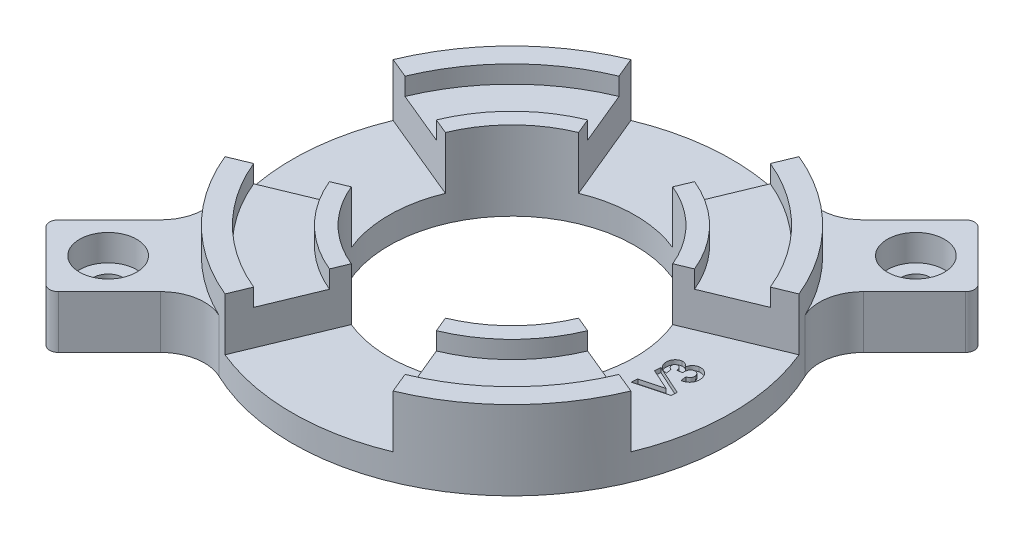
from build123d import *

# Parameters (mm, degrees)
SKETCH1_R                      = 25
SKETCH1_R_2                    = 14
BOSS_EXTRUDE1_DEPTH            = 7
SKETCH3_R                      = 25
SKETCH3_R_2                    = 22.5
BOSS_EXTRUDE2_DEPTH            = 2
SKETCH5_R                      = 15.9
SKETCH5_R_2                    = 14
BOSS_EXTRUDE3_DEPTH            = 2
CUT_EXTRUDE1_DEPTH             = 6
CIRPATTERN1_COUNT              = 4
BOSS_EXTRUDE4_DEPTH            = 6
CBORE_FOR_M3_SHCS1_D           = 3.4
CBORE_FOR_M3_SHCS1_CBORE_D     = 6.5
CBORE_FOR_M3_SHCS1_CBORE_DEPTH = 3
FILLET1_R                      = 5
FILLET1_OF_MIRROR1_R           = 5
FILLET2_R                      = 1
CUT_EXTRUDE2_DEPTH             = 0.5


with BuildPart() as part:
    # Sketch1 → Boss-Extrude1 (new body)
    with BuildSketch(Plane(origin=(0, 0, 0), x_dir=(1, 0, 0), z_dir=(0, 1, 0))):
        with Locations(Location((0, 0, 0), (0, 0, 270))):
            Circle(SKETCH1_R)
        with Locations(Location((0, 0, 0), (0, 0, 270))):
            Circle(SKETCH1_R_2, mode=Mode.SUBTRACT)
    extrude(amount=BOSS_EXTRUDE1_DEPTH)

    # Sketch3 → Boss-Extrude2 (add)
    with BuildSketch(Plane(origin=(0, 7, 0), x_dir=(1, 0, 0), z_dir=(0, 1, 0))):
        with Locations(Location((0, 0, 0), (0, 0, 270))):
            Circle(SKETCH3_R)
        with Locations(Location((0, 0, 0), (0, 0, 270))):
            Circle(SKETCH3_R_2, mode=Mode.SUBTRACT)
    extrude(amount=BOSS_EXTRUDE2_DEPTH)

    # Sketch5 → Boss-Extrude3 (add, through all)
    with BuildSketch(Plane(origin=(0, 7, 0), x_dir=(1, 0, 0), z_dir=(0, 1, 0))):
        with Locations(Location((0, 0, 0), (0, 0, 270))):
            Circle(SKETCH5_R)
        with Locations(Location((0, 0, 0), (0, 0, 270))):
            Circle(SKETCH5_R_2, mode=Mode.SUBTRACT)
    extrude(amount=BOSS_EXTRUDE3_DEPTH)

    # Sketch4 → Cut-Extrude1 (cut)
    with BuildSketch(Plane(origin=(0, 9, 0), x_dir=(1, 0, 0), z_dir=(0, 1, 0))):
        with BuildLine():
            Line((0, 0), (-9.567085809, 23.096988313))
            ThreePointArc((-9.567085809, 23.096988313), (0, 25), (9.567085809, 23.096988313))
            Line((9.567085809, 23.096988313), (0, 0))
        make_face()
    cut_extrude1 = extrude(amount=-CUT_EXTRUDE1_DEPTH, mode=Mode.SUBTRACT)

    # CirPattern1: Cut-Extrude1 ×4 about axis
    cirpattern1_axis = Axis((0, 9, 0), (0, -1, 0))
    for i in range(1, CIRPATTERN1_COUNT):
        add(cut_extrude1.rotate(cirpattern1_axis, i * 360 / CIRPATTERN1_COUNT), mode=Mode.SUBTRACT)

    # Sketch6 → Boss-Extrude4 (add)
    with BuildSketch(Plane.XZ):
        with BuildLine():
            Line((-30.0520382, 22.980970389), (-22.980970389, 30.0520382))
            Line((-22.980970389, 30.0520382), (-13.78497417, 20.856041982))
            ThreePointArc((-13.78497417, 20.856041982), (-17.67766953, 17.67766953), (-20.856041982, 13.78497417))
            Line((-20.856041982, 13.78497417), (-30.0520382, 22.980970389))
        make_face()
    boss_extrude4 = extrude(amount=-BOSS_EXTRUDE4_DEPTH)

    # CBORE for M3 SHCS1 (through all)
    with Locations(Plane(origin=(0, 6, 0), x_dir=(1, 0, 0), z_dir=(0, 1, 0))):
        with Locations((-22.980970389, -22.980970389)):
            cbore_for_m3_shcs1 = CounterBoreHole(CBORE_FOR_M3_SHCS1_D / 2, CBORE_FOR_M3_SHCS1_CBORE_D / 2, CBORE_FOR_M3_SHCS1_CBORE_DEPTH)

    # Fillet1
    fillet1_edges = [part.edges().sort_by_distance(p)[0] for p in [
        (-20.856041982, 3, 13.78497417),
        (-13.78497417, 3, 20.856041982),
    ]]
    fillet(fillet1_edges, radius=FILLET1_R)

    # Mirror1: Boss-Extrude4, CBORE for M3 SHCS1 across plane
    add(boss_extrude4.mirror(Plane(origin=(0, 0, 0), x_dir=(0.7071067811865439, 0, 0.7071067811865512), z_dir=(-0.7071067811865513, 0, 0.7071067811865438))))
    add(cbore_for_m3_shcs1.mirror(Plane(origin=(0, 0, 0), x_dir=(0.7071067811865439, 0, 0.7071067811865512), z_dir=(-0.7071067811865513, 0, 0.7071067811865438))), mode=Mode.SUBTRACT)

    # Fillet1 of Mirror1
    fillet1_of_mirror1_edges = [part.edges().sort_by_distance(p)[0] for p in [
        (13.78497417, 3, -20.856041982),
        (20.856041982, 3, -13.78497417),
    ]]
    fillet(fillet1_of_mirror1_edges, radius=FILLET1_OF_MIRROR1_R)

    # Fillet2
    fillet2_edges = [part.edges().sort_by_distance(p)[0] for p in [
        (-30.0520382, 3, 22.980970389),
        (-22.980970389, 3, 30.0520382),
        (22.980970389, 3, -30.0520382),
        (30.0520382, 3, -22.980970389),
    ]]
    fillet(fillet2_edges, radius=FILLET2_R)

    # Sketch9 → Cut-Extrude2 (cut)
    with BuildSketch(Plane(origin=(0, 3, 0), x_dir=(1, 0, 0), z_dir=(0, 1, 0))):
        with BuildLine():
            Line((17.259954439, 0.862539798), (17.348996907, 0.231530183))
            add(Edge.make_bspline(
                [(17.348996907, 0.231530183), (17.317190322, 0.231740342), (17.254858557, 0.232152192), (17.163308737, 0.241102274), (17.075558399, 0.25463813), (16.99163939, 0.275177512), (16.911539514, 0.30161435), (16.835745352, 0.334887447), (16.763376301, 0.373276256), (16.718648146, 0.404031504), (16.696252516, 0.419430824)],
                knots=[0, 0, 0, 0, 1.104049126, 2.163619036, 3.19102687, 4.185100227, 5.160376032, 6.116312538, 7.05682746, 8, 8, 8, 8], degree=3))
            add(Edge.make_bspline(
                [(16.696252516, 0.419430824), (16.666804548, 0.442488088), (16.608711096, 0.487974283), (16.530370427, 0.565195798), (16.46106221, 0.64878225), (16.402432313, 0.739801065), (16.351979583, 0.836259963), (16.312151624, 0.93961249), (16.280900509, 1.049211498), (16.268079961, 1.125306067), (16.261557003, 1.16402217)],
                knots=[0, 0, 0, 0, 1.011718373, 1.995866484, 2.971089056, 3.944915401, 4.921060848, 5.912561991, 6.93793387, 8, 8, 8, 8], degree=3))
            add(Edge.make_bspline(
                [(16.261557003, 1.16402217), (16.257415074, 1.198795237), (16.249262297, 1.267240885), (16.24814513, 1.369141377), (16.255707885, 1.467955277), (16.272525842, 1.563805515), (16.29872656, 1.656420787), (16.332819131, 1.746303431), (16.377825966, 1.831950288), (16.42982656, 1.914276441), (16.489039782, 1.990517568), (16.552634563, 2.060074295), (16.622111223, 2.119405039), (16.694301, 2.172305308), (16.77222235, 2.215172021), (16.854352689, 2.249310973), (16.940695825, 2.2760467), (17.000389607, 2.286248182), (17.030687612, 2.291426016)],
                knots=[0, 0, 0, 0, 1.10699972, 2.178965478, 3.217058015, 4.237926321, 5.251300092, 6.257558012, 7.272548182, 8.306103856, 9.333721029, 10.322310713, 11.281271299, 12.218794739, 13.148592653, 14.086261795, 15.028668506, 16, 16, 16, 16], degree=3))
            add(Edge.make_bspline(
                [(17.030687612, 2.291426016), (17.068515519, 2.295149188), (17.143258563, 2.302505693), (17.255136461, 2.293361156), (17.364091545, 2.2686283), (17.469483288, 2.226957284), (17.569897425, 2.169098348), (17.664199904, 2.095976477), (17.7511794, 2.006917393), (17.800903834, 1.938281523), (17.826460849, 1.903004542)],
                knots=[0, 0, 0, 0, 0.973519072, 1.923547578, 2.864565826, 3.830969356, 4.819293423, 5.827869, 6.883583398, 8, 8, 8, 8], degree=3))
            add(Edge.make_bspline(
                [(17.826460849, 1.903004542), (17.830972671, 1.929729661), (17.839864787, 1.982400821), (17.859859353, 2.058947824), (17.883895981, 2.132159659), (17.91469763, 2.200874445), (17.948694984, 2.266792778), (17.989160917, 2.328163842), (18.033027549, 2.387039908), (18.083158087, 2.440693071), (18.136937795, 2.490548247), (18.194591881, 2.53529306), (18.254980901, 2.575682962), (18.319069102, 2.610206666), (18.386944576, 2.638672001), (18.457692335, 2.663546546), (18.532073117, 2.682566297), (18.583126752, 2.690542468), (18.608912772, 2.694571048)],
                knots=[0, 0, 0, 0, 1.083540701, 2.135494505, 3.161206298, 4.161560271, 5.144156765, 6.124215683, 7.098238184, 8.077271306, 9.056304428, 10.02862103, 10.993042575, 11.959138739, 12.93490893, 13.934083059, 14.956552702, 16, 16, 16, 16], degree=3))
            add(Edge.make_bspline(
                [(18.608912772, 2.694571048), (18.646954957, 2.69886286), (18.72218277, 2.707349848), (18.834555102, 2.706258989), (18.944009058, 2.694372058), (19.050493282, 2.671529415), (19.153446682, 2.63545419), (19.254287591, 2.590322244), (19.351344872, 2.531933619), (19.444649481, 2.463548532), (19.532479261, 2.386627888), (19.611754744, 2.301145831), (19.681046378, 2.207907445), (19.742960094, 2.108367028), (19.792882423, 2.000044431), (19.835118093, 1.885496572), (19.868720004, 1.763604414), (19.882253028, 1.679042883), (19.88916117, 1.635877138)],
                knots=[0, 0, 0, 0, 0.990009335, 1.95772769, 2.900808091, 3.835629367, 4.769001702, 5.719038207, 6.689907732, 7.693968782, 8.709567083, 9.70677377, 10.704713832, 11.711921304, 12.734626295, 13.785138182, 14.869389445, 16, 16, 16, 16], degree=3))
            add(Edge.make_bspline(
                [(19.88916117, 1.635877138), (19.894093201, 1.594804656), (19.903737272, 1.514491731), (19.905687314, 1.395221726), (19.897134734, 1.280550736), (19.879636323, 1.169897538), (19.849232452, 1.064386541), (19.811169757, 0.962385277), (19.760820115, 0.865669796), (19.701320607, 0.773765266), (19.632643143, 0.68808285), (19.555066787, 0.610164882), (19.469975911, 0.539371626), (19.375998543, 0.477874948), (19.274633764, 0.423343837), (19.164496423, 0.378115291), (19.04659601, 0.33993518), (18.964321612, 0.321547508), (18.922314215, 0.312159189)],
                knots=[0, 0, 0, 0, 1.083784843, 2.119227433, 3.120453703, 4.095321291, 5.049549174, 5.993834545, 6.944536155, 7.901159972, 8.859782349, 9.817092416, 10.778704846, 11.755648913, 12.755975239, 13.791254726, 14.872265962, 16, 16, 16, 16], degree=3))
            Line((18.922314215, 0.312159189), (18.831168381, 0.961397971))
            add(Edge.make_bspline(
                [(18.831168381, 0.961397971), (18.852314441, 0.968096511), (18.893453191, 0.981128231), (18.951572332, 1.005304662), (19.005582851, 1.031067823), (19.054311972, 1.060323447), (19.098156727, 1.092299957), (19.138055567, 1.126016887), (19.172939294, 1.162885855), (19.212330016, 1.215727566), (19.251060914, 1.287312507), (19.28060214, 1.381232066), (19.2909831, 1.482533774), (19.284588539, 1.551307412), (19.281288574, 1.586798613)],
                knots=[0, 0, 0, 0, 0.936984204, 1.822862454, 2.657719528, 3.463985831, 4.220632404, 4.949100381, 5.668743832, 6.360111482, 7.730089342, 9.085823426, 10.496115217, 12, 12, 12, 12], degree=3))
            add(Edge.make_bspline(
                [(19.281288574, 1.586798613), (19.278055535, 1.605549051), (19.271739335, 1.642180703), (19.257794071, 1.695399829), (19.23881591, 1.745138369), (19.215481788, 1.7918307), (19.18799243, 1.835497973), (19.156471997, 1.876290032), (19.120513212, 1.91367706), (19.080458257, 1.947041566), (19.038127482, 1.976979752), (18.99382754, 2.002850629), (18.947272695, 2.021819313), (18.900216091, 2.038074614), (18.851332, 2.047302974), (18.801438954, 2.053422641), (18.749919644, 2.053246182), (18.71545685, 2.049392625), (18.69795524, 2.047435632)],
                knots=[0, 0, 0, 0, 1.100775537, 2.150521839, 3.177813434, 4.175754214, 5.166336805, 6.159132579, 7.153860849, 8.161649967, 9.170980534, 10.152287803, 11.121876151, 12.075583343, 13.027755082, 13.994036663, 14.981290177, 16, 16, 16, 16], degree=3))
            add(Edge.make_bspline(
                [(18.69795524, 2.047435632), (18.678908109, 2.044185747), (18.641184881, 2.037749284), (18.587028872, 2.019578553), (18.53545453, 1.99671301), (18.487356084, 1.966968956), (18.44314091, 1.930637006), (18.401307754, 1.889232418), (18.363518721, 1.840867135), (18.328592125, 1.787382545), (18.298135251, 1.728080161), (18.273941496, 1.663525282), (18.254897228, 1.59430809), (18.241649971, 1.520150308), (18.234202889, 1.440905742), (18.231998848, 1.356790745), (18.236661236, 1.267837362), (18.243105707, 1.207230725), (18.246432804, 1.175941241)],
                knots=[0, 0, 0, 0, 0.845631791, 1.674790894, 2.495302089, 3.313893358, 4.14406394, 4.998641853, 5.887986975, 6.828300498, 7.794799959, 8.802947587, 9.844060587, 10.936934965, 12.099751272, 13.329174956, 14.621128922, 16, 16, 16, 16], degree=3))
            Line((18.246432804, 1.175941241), (17.684133125, 1.096714478))
            add(Edge.make_bspline(
                [(17.684133125, 1.096714478), (17.675555743, 1.13331789), (17.659522363, 1.201739278), (17.629197594, 1.295382833), (17.59772352, 1.373677783), (17.562801972, 1.437679844), (17.523644867, 1.489238685), (17.482096724, 1.533631886), (17.435618968, 1.570449974), (17.384855973, 1.598707985), (17.332674058, 1.62117103), (17.27878161, 1.633327668), (17.224684879, 1.639133981), (17.18890159, 1.63556702), (17.170911971, 1.633773773)],
                knots=[0, 0, 0, 0, 1.639904863, 3.065412797, 4.290785113, 5.317986534, 6.235837344, 7.108674852, 7.965578391, 8.810565059, 9.63820311, 10.434719109, 11.213073807, 12, 12, 12, 12], degree=3))
            add(Edge.make_bspline(
                [(17.170911971, 1.633773773), (17.148423933, 1.629606559), (17.104578323, 1.621481617), (17.044481681, 1.592997138), (16.992173206, 1.553682683), (16.948827972, 1.503713897), (16.915440858, 1.445214139), (16.895059479, 1.379250041), (16.887154064, 1.307085099), (16.892097578, 1.257719081), (16.894669984, 1.232030984)],
                knots=[0, 0, 0, 0, 1.000847401, 1.951382476, 2.889479326, 3.856930728, 4.835909801, 5.825963227, 6.86871844, 8, 8, 8, 8], degree=3))
            add(Edge.make_bspline(
                [(16.894669984, 1.232030984), (16.89907775, 1.209166249), (16.907781137, 1.164018512), (16.933641798, 1.099891066), (16.970213124, 1.041123004), (17.015323715, 0.987466521), (17.068382354, 0.94140471), (17.127392769, 0.904299485), (17.191628546, 0.877163739), (17.237079212, 0.867435833), (17.259954439, 0.862539798)],
                knots=[0, 0, 0, 0, 1.005034831, 1.984499135, 2.968850652, 3.987056738, 5.004159185, 5.99383813, 6.99030282, 8, 8, 8, 8], degree=3))
        make_face()
        Polygon((16.246074602, -2.668624998), (16.299359858, -1.987134613), (18.841627486, -1.30634535), (16.438181973, -0.224514421), (16.492168352, 0.456975964), (19.87437989, -1.070768427), (19.823899121, -1.710191504), align=None)
    extrude(amount=-CUT_EXTRUDE2_DEPTH, mode=Mode.SUBTRACT)


solid = part.part
